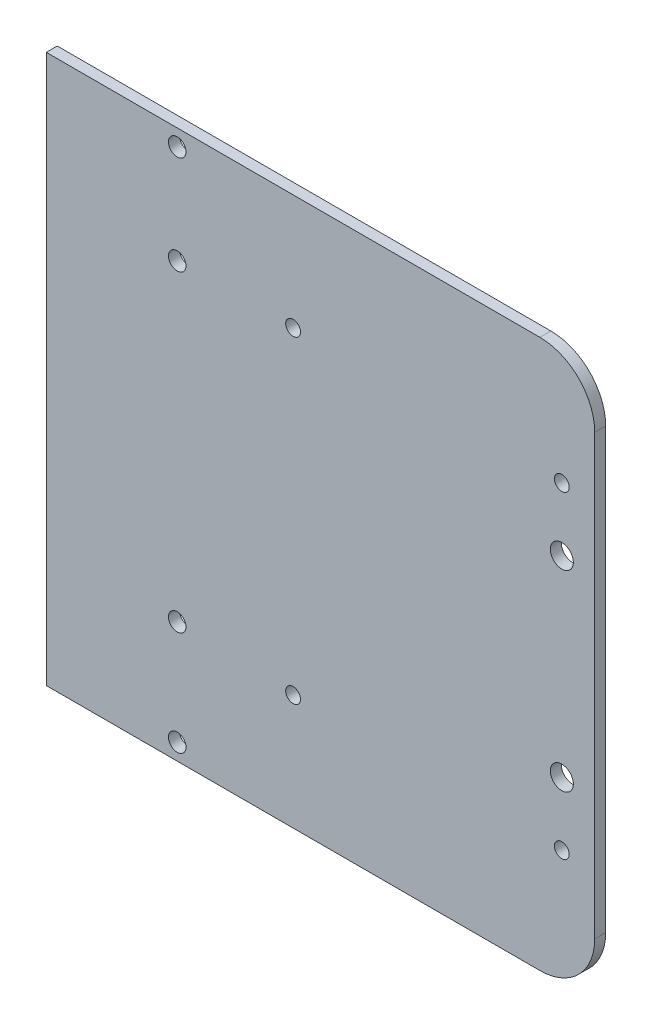
from build123d import *

# Parameters (mm, degrees)
EXTRUDE_1_DEPTH     = 2
SKETCH_3_R          = 1.35
CUT_EXTRUDE_1_DEPTH = 3
SKETCH_7_R          = 2.1
CUT_EXTRUDE_5_DEPTH = 10
SKETCH_8_R          = 1.6
CUT_EXTRUDE_6_DEPTH = 3


with BuildPart() as part:
    # 草图1 → 凸台-拉伸1 (new body)
    with BuildSketch(Plane.XY):
        with BuildLine():
            Line((-50, 50), (40, 50))
            ThreePointArc((40, 50), (47.071067812, 47.071067812), (50, 40))
            Line((50, 40), (50, -40))
            ThreePointArc((50, -40), (47.071067812, -47.071067812), (40, -50))
            Line((40, -50), (-50, -50))
            Line((-50, -50), (-50, 50))
        make_face()
    extrude(amount=EXTRUDE_1_DEPTH)

    # 草图3 → 切除-拉伸1 (cut, through all)
    with BuildSketch(Plane.XY.offset(2)):
        with Locations((-5, -29)):
            Circle(SKETCH_3_R)
        with Locations((-5, 29)):
            Circle(SKETCH_3_R)
        with Locations((44, 29)):
            Circle(SKETCH_3_R)
        with Locations((44, -29)):
            Circle(SKETCH_3_R)
    extrude(amount=-CUT_EXTRUDE_1_DEPTH, mode=Mode.SUBTRACT)

    # 草图7 → 切除-拉伸5 (cut)
    with BuildSketch(Plane.XY.offset(2)):
        with Locations((44, 17.5)):
            Circle(SKETCH_7_R)
        with Locations((44, -17.5)):
            Circle(SKETCH_7_R)
    extrude(amount=-CUT_EXTRUDE_5_DEPTH, mode=Mode.SUBTRACT)

    # 草图8 → 切除-拉伸6 (cut, through all)
    with BuildSketch(Plane(origin=(0, 0, 0), x_dir=(-1, 0, 0), z_dir=(0, 0, -1))):
        with Locations((26.125, -47)):
            Circle(SKETCH_8_R)
        with Locations((26.125, -28)):
            Circle(SKETCH_8_R)
        with Locations((26.125, 29)):
            Circle(SKETCH_8_R)
        with Locations((26.125, 47)):
            Circle(SKETCH_8_R)
    extrude(amount=-CUT_EXTRUDE_6_DEPTH, mode=Mode.SUBTRACT)


solid = part.part
